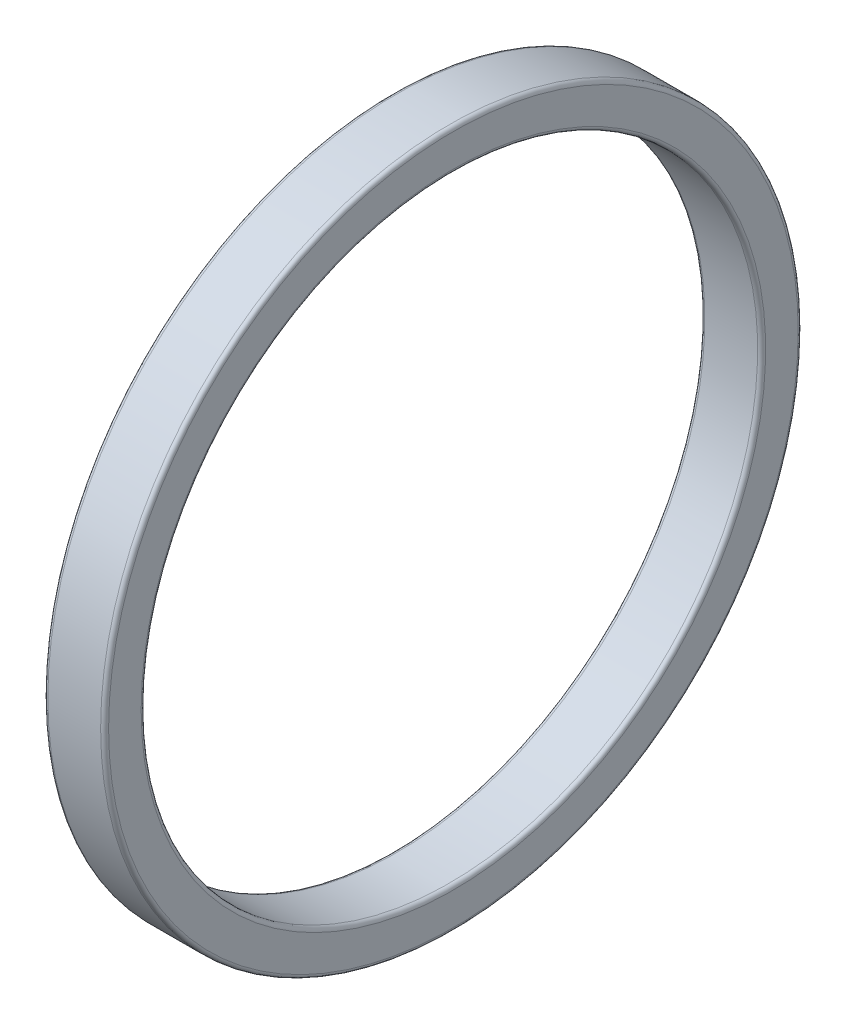
from build123d import *


with BuildPart() as part:
    # Sketch2 → Revolve1 (revolve)
    with BuildSketch(Plane.XY):
        with BuildLine():
            Line((-279.415408807, 15.4572), (-276.767408807, 15.4572))
            ThreePointArc((-276.767408807, 15.4572), (-276.625987451, 15.515778644), (-276.567408807, 15.6572))
            Line((-276.567408807, 15.6572), (-276.567408807, 17.2892))
            ThreePointArc((-276.567408807, 17.2892), (-276.625987451, 17.430621356), (-276.767408807, 17.4892))
            Line((-276.767408807, 17.4892), (-279.415408807, 17.4892))
            ThreePointArc((-279.415408807, 17.4892), (-279.556830163, 17.430621356), (-279.615408807, 17.2892))
            Line((-279.615408807, 17.2892), (-279.615408807, 15.6572))
            ThreePointArc((-279.615408807, 15.6572), (-279.556830163, 15.515778644), (-279.415408807, 15.4572))
        make_face()
    revolve(axis=Axis((-295.311631148, 0, 0), (1, 0, 0)))


solid = part.part
